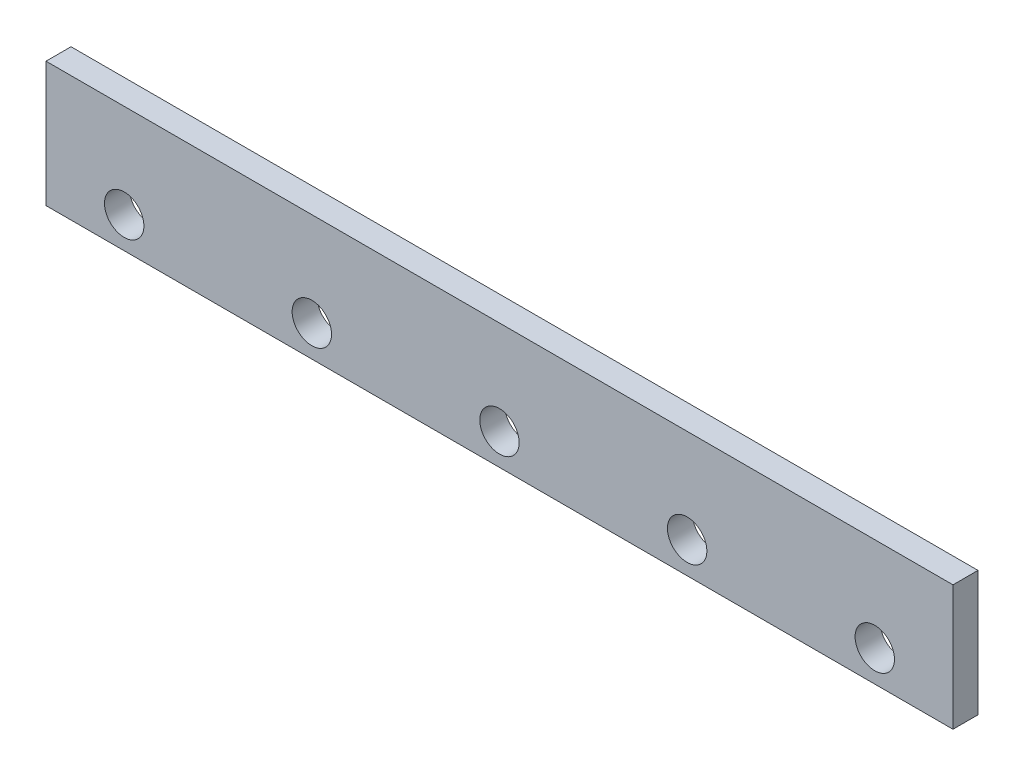
from build123d import *

# Parameters (mm, degrees)
SKETCH1_W           = 580
SKETCH1_H           = 80
BOSS_EXTRUDE1_DEPTH = 16
SKETCH2_R           = 12.6
CUT_EXTRUDE7_DEPTH  = 16


with BuildPart() as part:
    # Sketch1 → Boss-Extrude1 (new body)
    with BuildSketch(Plane.XY):
        with Locations((290, 40)):
            Rectangle(SKETCH1_W, SKETCH1_H)
    extrude(amount=BOSS_EXTRUDE1_DEPTH)

    # Sketch2 → Cut-Extrude7 (cut)
    with BuildSketch(Plane.XY):
        with Locations((50, 20)):
            Circle(SKETCH2_R)
        with Locations((170, 20)):
            Circle(SKETCH2_R)
        with Locations((290, 20)):
            Circle(SKETCH2_R)
        with Locations((410, 20)):
            Circle(SKETCH2_R)
        with Locations((530, 20)):
            Circle(SKETCH2_R)
    extrude(amount=CUT_EXTRUDE7_DEPTH, mode=Mode.SUBTRACT)


solid = part.part
